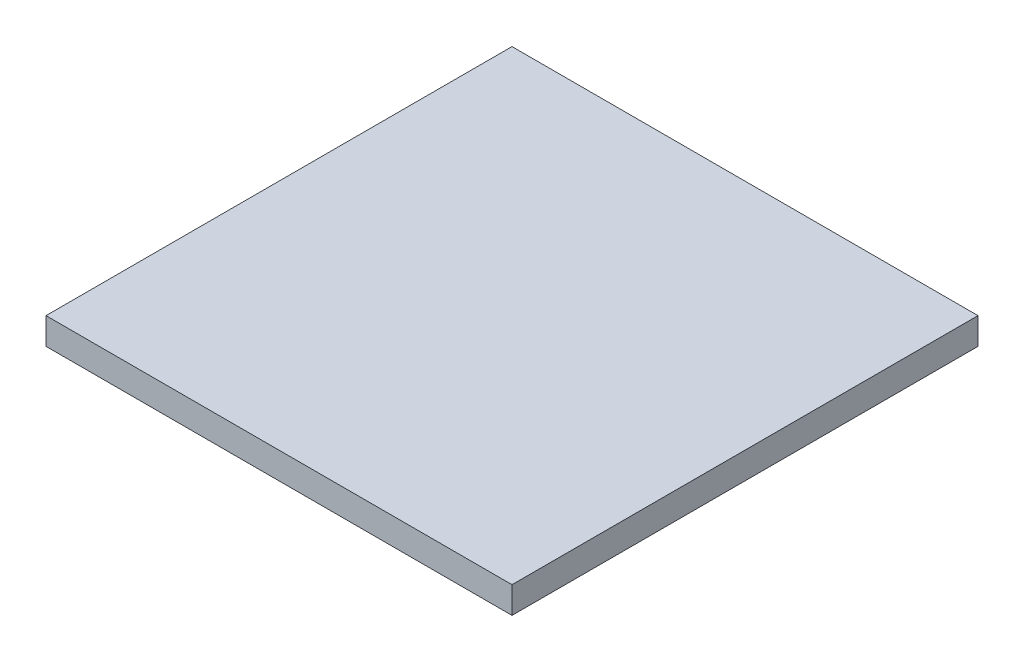
from build123d import *

# Parameters (mm, degrees)
SKETCH1_W           = 35
SKETCH1_H           = 35
BOSS_EXTRUDE1_DEPTH = 2


with BuildPart() as part:
    # Sketch1 → Boss-Extrude1 (new body)
    with BuildSketch(Plane(origin=(0, 0, 0), x_dir=(1, 0, 0), z_dir=(0, 1, 0))):
        Rectangle(SKETCH1_W, SKETCH1_H)
    extrude(amount=BOSS_EXTRUDE1_DEPTH)


solid = part.part
